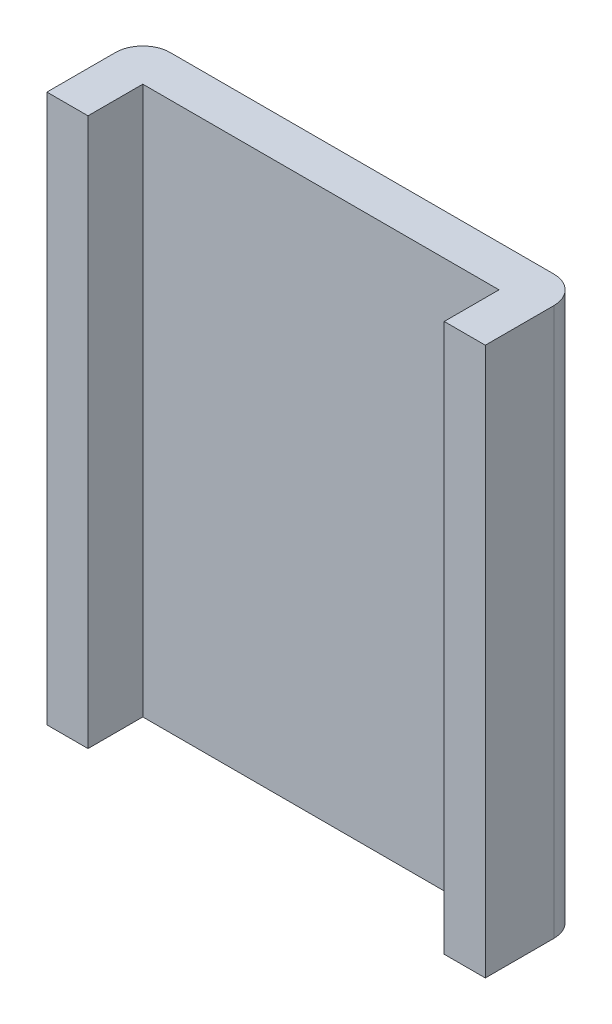
from build123d import *

# Parameters (mm, degrees)
SKETCH1_W           = 6.5
SKETCH1_H           = 10
BOSS_EXTRUDE1_DEPTH = 0.75
SKETCH1_3_W         = 0.75
SKETCH1_3_H         = 10
BOSS_EXTRUDE2_DEPTH = 1.75
FILLET1_R           = 0.5


with BuildPart() as part:
    # Sketch1 → Boss-Extrude1 (new body)
    with BuildSketch(Plane.XY):
        Rectangle(SKETCH1_W, SKETCH1_H)
    extrude(amount=BOSS_EXTRUDE1_DEPTH)

    # Sketch1_3 → Boss-Extrude2 (add)
    with BuildSketch(Plane.XY):
        with Locations((-3.625, 0)):
            Rectangle(SKETCH1_3_W, SKETCH1_3_H)
        with Locations((3.625, 0)):
            Rectangle(SKETCH1_3_W, SKETCH1_3_H)
    extrude(amount=BOSS_EXTRUDE2_DEPTH)

    # Fillet1
    fillet1_edges = [part.edges().sort_by_distance(p)[0] for p in [
        (-4, 0, 0),
        (4, 0, 0),
    ]]
    fillet(fillet1_edges, radius=FILLET1_R)


solid = part.part
